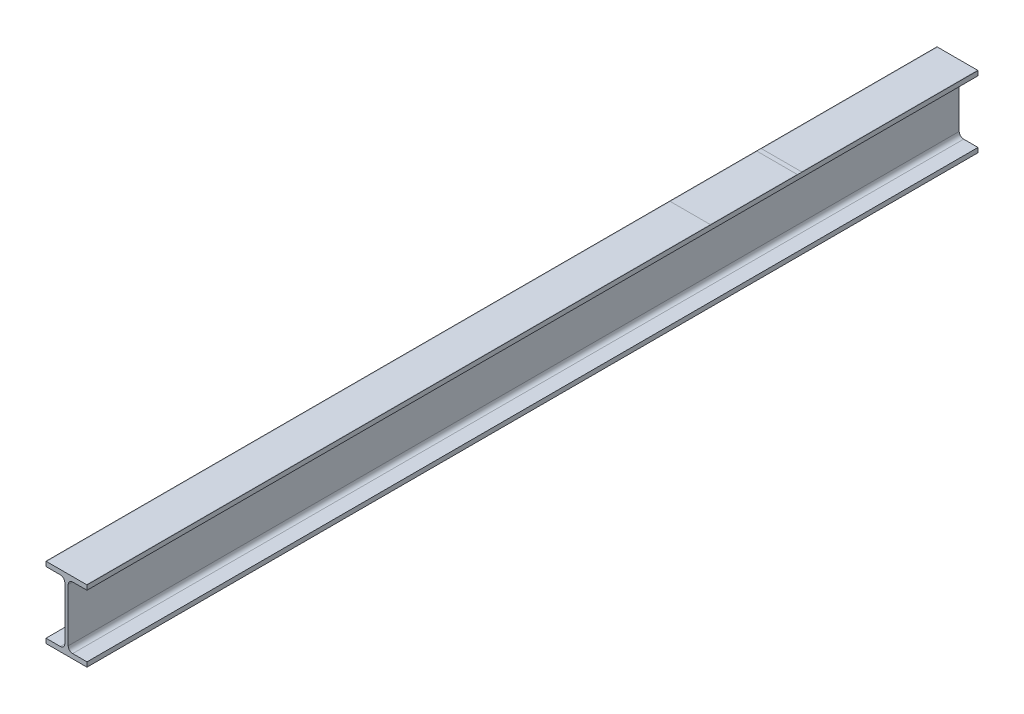
from build123d import *

# Parameters (mm, degrees)
LINEAR_AUSTRAGEN1_DEPTH = 1000


with BuildPart() as part:
    # Skizze1 → Linear austragen1 (new body)
    with BuildSketch(Plane.XY):
        with BuildLine():
            Line((0, 0), (0, 5.2))
            Line((0, 5.2), (16.1, 5.2))
            ThreePointArc((16.1, 5.2), (19.635533906, 6.664466094), (21.1, 10.2))
            Line((21.1, 10.2), (21.1, 69.8))
            ThreePointArc((21.1, 69.8), (19.635533906, 73.335533906), (16.1, 74.8))
            Line((16.1, 74.8), (0, 74.8))
            Line((0, 74.8), (0, 80))
            Line((0, 80), (46, 80))
            Line((46, 80), (46, 74.8))
            Line((46, 74.8), (29.9, 74.8))
            ThreePointArc((29.9, 74.8), (26.364466094, 73.335533906), (24.9, 69.8))
            Line((24.9, 69.8), (24.9, 10.2))
            ThreePointArc((24.9, 10.2), (26.364466094, 6.664466094), (29.9, 5.2))
            Line((29.9, 5.2), (46, 5.2))
            Line((46, 5.2), (46, 0))
            Line((46, 0), (0, 0))
        make_face()
    extrude(amount=LINEAR_AUSTRAGEN1_DEPTH)


solid = part.part
